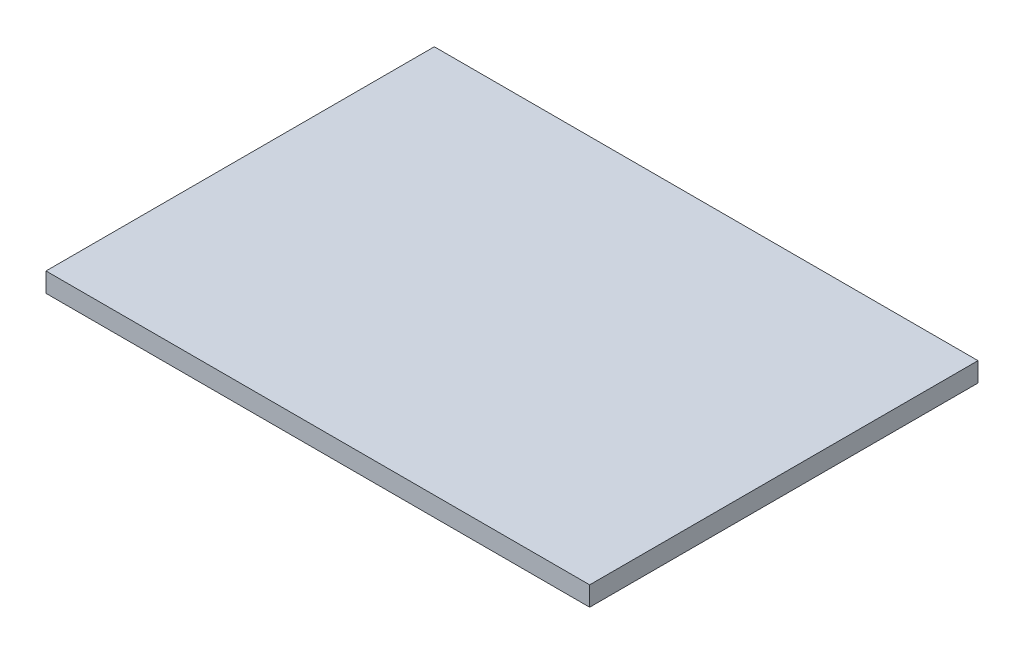
from build123d import *

# Parameters (mm, degrees)
SKETCH1_W           = 355.6
SKETCH1_H           = 254
BOSS_EXTRUDE1_DEPTH = 12.7


with BuildPart() as part:
    # Sketch1 → Boss-Extrude1 (new body)
    with BuildSketch(Plane(origin=(0, 0, 0), x_dir=(1, 0, 0), z_dir=(0, 1, 0))):
        Rectangle(SKETCH1_W, SKETCH1_H)
    extrude(amount=BOSS_EXTRUDE1_DEPTH)


solid = part.part
